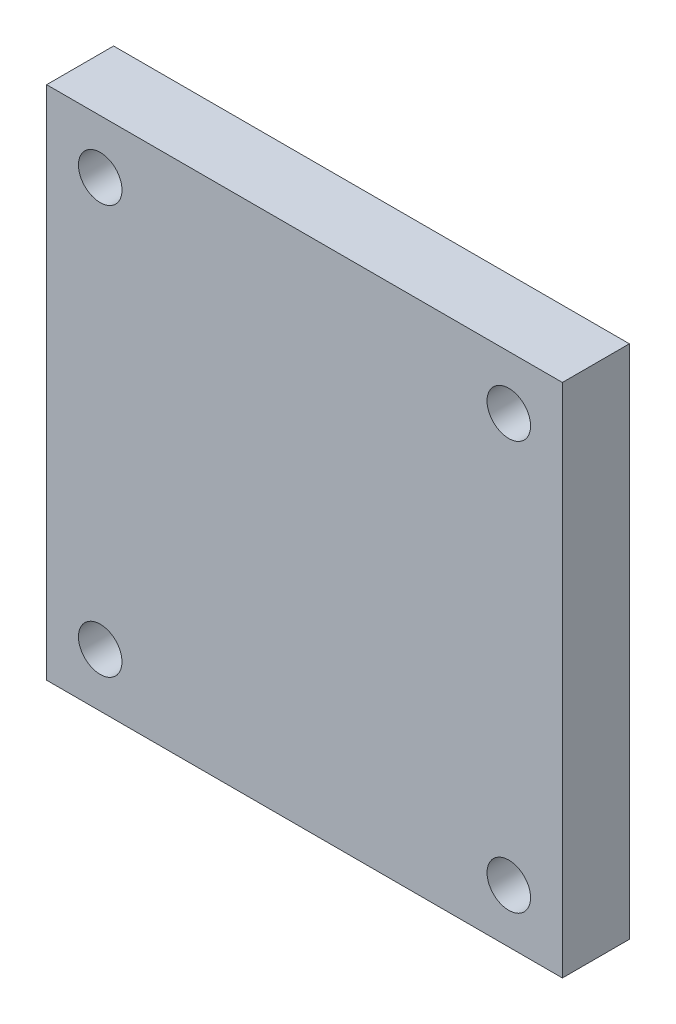
from build123d import *

# Parameters (mm, degrees)
SKETCH1_W           = 154
SKETCH1_H           = 154
SKETCH1_R           = 6.5
BOSS_EXTRUDE1_DEPTH = 10


with BuildPart() as part:
    # Sketch1 → Boss-Extrude1 (new body, symmetric)
    with BuildSketch(Plane.XY):
        Rectangle(SKETCH1_W, SKETCH1_H)
        with Locations((-61, 61)):
            Circle(SKETCH1_R, mode=Mode.SUBTRACT)
        with Locations((61, 61)):
            Circle(SKETCH1_R, mode=Mode.SUBTRACT)
        with Locations((-61, -61)):
            Circle(SKETCH1_R, mode=Mode.SUBTRACT)
        with Locations((61, -61)):
            Circle(SKETCH1_R, mode=Mode.SUBTRACT)
    extrude(amount=BOSS_EXTRUDE1_DEPTH, both=True)


solid = part.part
